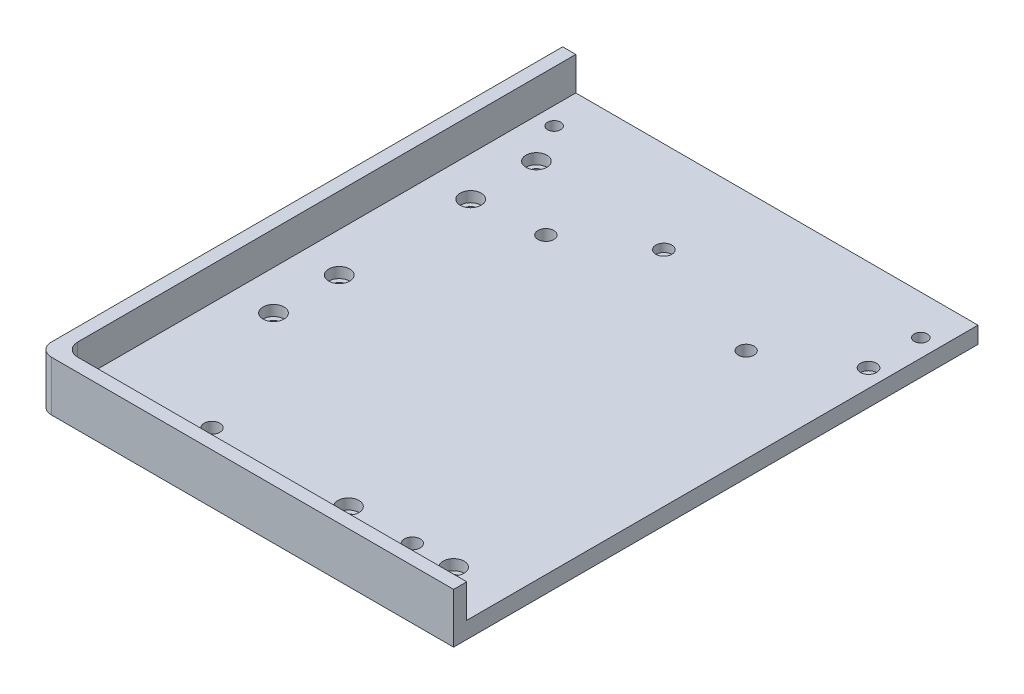
from build123d import *

# Parameters (mm, degrees)
SKETCH1_W                      = 158
SKETCH1_H                      = 199.5
BOSS_EXTRUDE1_DEPTH            = 6.35
BOSS_EXTRUDE2_DEPTH            = 12.7
CBORE_FOR_M4_SHCS1_D           = 4.5
CBORE_FOR_M4_SHCS1_DEPTH       = 6.35
CBORE_FOR_M4_SHCS1_CBORE_D     = 8
CBORE_FOR_M4_SHCS1_CBORE_DEPTH = 4
FILLET2_R                      = 5
SKETCH8_R                      = 3
ENCLOSURE_MOUNT_DEPTH          = 7.35
SKETCH9_R                      = 2.5
FUSE_MOUNT_DEPTH               = 7.35
SKETCH10_R                     = 3.05
MAGNETS_DEPTH                  = 3.1


with BuildPart() as part:
    # Sketch1 → Boss-Extrude1 (new body)
    with BuildSketch(Plane(origin=(0, 0, 0), x_dir=(1, 0, 0), z_dir=(0, 1, 0))):
        with Locations((79, -99.75)):
            Rectangle(SKETCH1_W, SKETCH1_H)
    extrude(amount=BOSS_EXTRUDE1_DEPTH)

    # Sketch3 → Boss-Extrude2 (add)
    with BuildSketch(Plane(origin=(0, 6.35, 0), x_dir=(1, 0, 0), z_dir=(0, 1, 0))):
        Polygon((0, 0), (0, -199.5), (158, -199.5), (158, -194.5), (5, -194.5), (5, 0), align=None)
    extrude(amount=BOSS_EXTRUDE2_DEPTH)

    # CBORE for M4 SHCS1
    with Locations(Plane(origin=(0, 6.35, 0), x_dir=(1, 0, 0), z_dir=(0, 1, 0))):
        with Locations((20, -55), (98, -179.5), (138, -179.5), (20, -130), (20, -105), (20, -30)):
            CounterBoreHole(CBORE_FOR_M4_SHCS1_D / 2, CBORE_FOR_M4_SHCS1_CBORE_D / 2, CBORE_FOR_M4_SHCS1_CBORE_DEPTH, depth=CBORE_FOR_M4_SHCS1_DEPTH)

    # Fillet2
    fillet2_edges = [part.edges().sort_by_distance(p)[0] for p in [
        (5, 12.7, 194.5),
        (0, 9.525, 199.5),
    ]]
    fillet(fillet2_edges, radius=FILLET2_R)

    # Sketch8 → Enclosure Mount (cut, through all)
    with BuildSketch(Plane(origin=(0, 6.35, 0), x_dir=(1, 0, 0), z_dir=(0, 1, 0))):
        with Locations((46.1, -52.5)):
            Circle(SKETCH8_R)
        with Locations((122.3, -52.5)):
            Circle(SKETCH8_R)
        with Locations((122.3, -179.5)):
            Circle(SKETCH8_R)
        with Locations((46.1, -179.5)):
            Circle(SKETCH8_R)
    extrude(amount=-ENCLOSURE_MOUNT_DEPTH, mode=Mode.SUBTRACT)

    # Sketch9 → Fuse Mount (cut, through all)
    with BuildSketch(Plane(origin=(0, 6.35, 0), x_dir=(1, 0, 0), z_dir=(0, 1, 0))):
        with Locations((11.75, -15)):
            Circle(SKETCH9_R)
        with Locations((151.25, -15)):
            Circle(SKETCH9_R)
    extrude(amount=-FUSE_MOUNT_DEPTH, mode=Mode.SUBTRACT)

    # Sketch10 → Magnets (cut)
    with BuildSketch(Plane(origin=(0, 6.35, 0), x_dir=(1, 0, 0), z_dir=(0, 1, 0))):
        with Locations((151.25, -34.9)):
            Circle(SKETCH10_R)
        with Locations((73.375, -34.9)):
            Circle(SKETCH10_R)
    extrude(amount=-MAGNETS_DEPTH, mode=Mode.SUBTRACT)


solid = part.part
